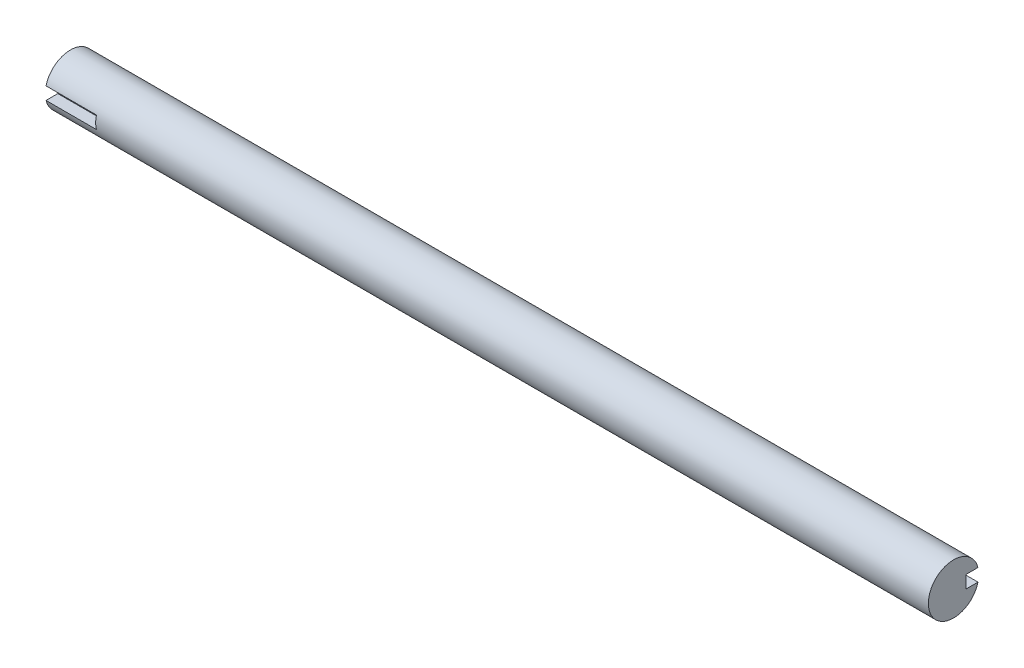
from build123d import *

# Parameters (mm, degrees)
SKETCH1_R           = 10
BOSS_EXTRUDE1_DEPTH = 350
SKETCH2_W           = 10
SKETCH2_H           = 5
CUT_EXTRUDE1_DEPTH  = 20
SKETCH3_W           = 10
SKETCH3_H           = 5
CUT_EXTRUDE2_DEPTH  = 20


with BuildPart() as part:
    # Sketch1 → Boss-Extrude1 (new body)
    with BuildSketch(Plane(origin=(0, 0, 0), x_dir=(0, 0, -1), z_dir=(1, 0, 0))):
        Circle(SKETCH1_R)
    extrude(amount=BOSS_EXTRUDE1_DEPTH)

    # Sketch2 → Cut-Extrude1 (cut)
    with BuildSketch(Plane.ZY):
        with Locations((10, 0)):
            Rectangle(SKETCH2_W, SKETCH2_H)
    extrude(amount=-CUT_EXTRUDE1_DEPTH, mode=Mode.SUBTRACT)

    # Sketch3 → Cut-Extrude2 (cut)
    with BuildSketch(Plane(origin=(350, 0, 0), x_dir=(0, 0, -1), z_dir=(1, 0, 0))):
        with Locations((10, 0)):
            Rectangle(SKETCH3_W, SKETCH3_H)
    extrude(amount=-CUT_EXTRUDE2_DEPTH, mode=Mode.SUBTRACT)


solid = part.part
